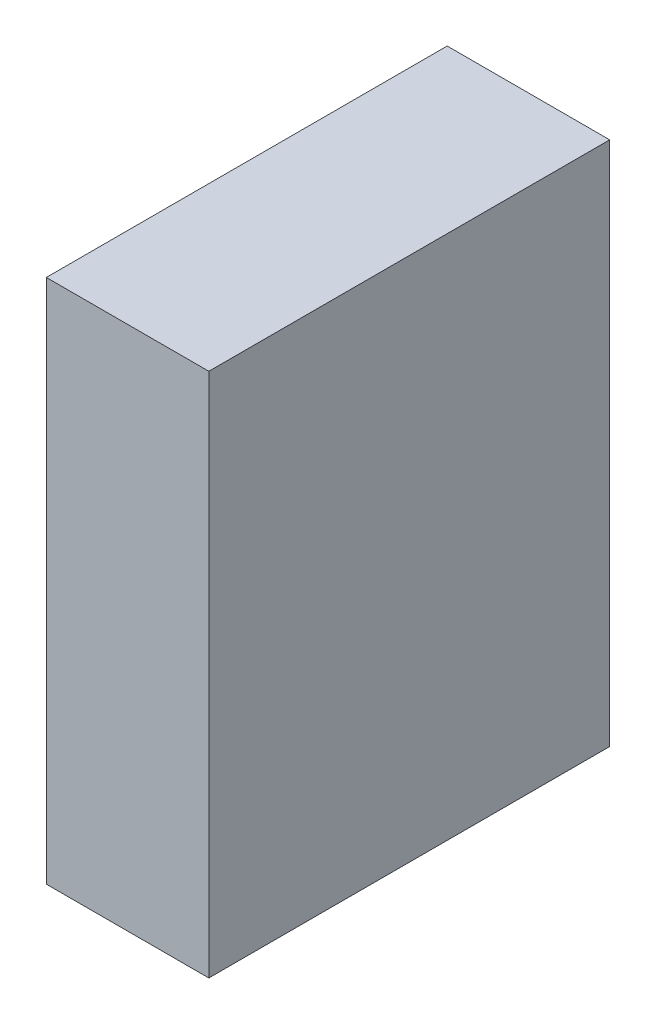
from build123d import *

# Parameters (mm, degrees)
ESQUISSE1_W        = 74
ESQUISSE1_H        = 97
BOSS_EXTRU_1_DEPTH = 30


with BuildPart() as part:
    # Esquisse1 → Boss.-Extru.1 (new body)
    with BuildSketch(Plane(origin=(0, 0, 0), x_dir=(0, 0, -1), z_dir=(1, 0, 0))):
        Rectangle(ESQUISSE1_W, ESQUISSE1_H)
    extrude(amount=BOSS_EXTRU_1_DEPTH)


solid = part.part
